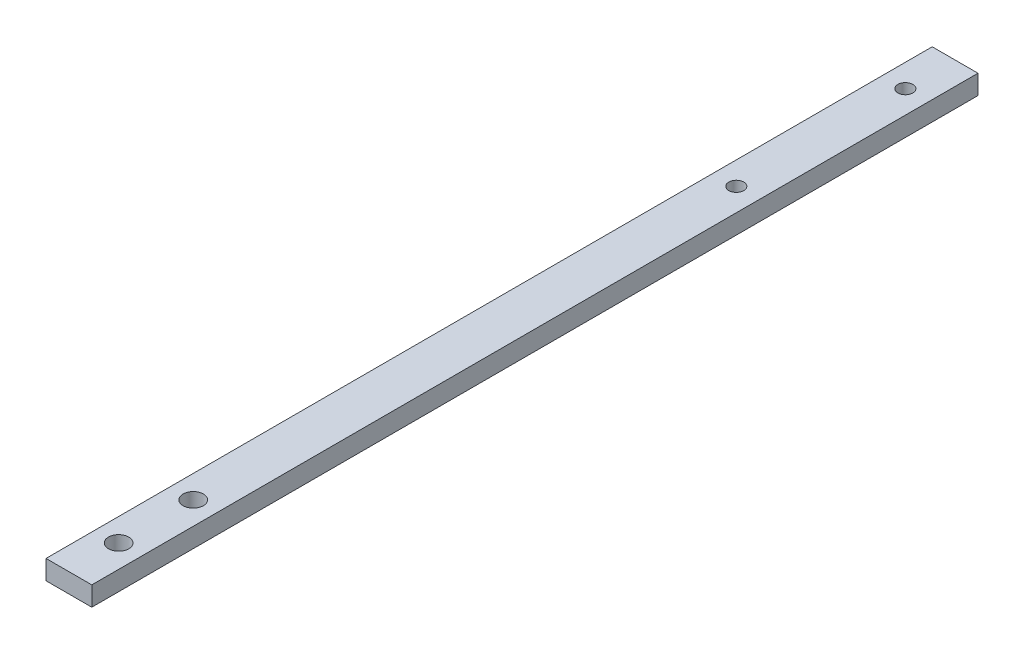
from build123d import *

# Parameters (mm, degrees)
SKETCH1_R               = 2.5
BOSS_EXTRUDE1_DEPTH     = 56
SKETCH2_W               = 4.604836256
SKETCH2_H               = 1.948199954
BOSS_EXTRUDE2_DEPTH     = 33.1
SKETCH3_R               = 1.022717979
CUT_EXTRUDE1_DEPTH      = 4.474099977
SKETCH4_R               = 0.75
CUT_EXTRUDE2_DEPTH      = 3.5
CUT_EXTRUDE2_DEPTH_BACK = 3.5
SKETCH5_OUTSIDE_W       = 24.876
SKETCH5_OUTSIDE_H       = 24.876
SKETCH5_OUTSIDE_W_2     = 4.604836256
SKETCH5_OUTSIDE_H_2     = 1.948199954
CUT_EXTRUDE3_DEPTH      = 90.1000001


with BuildPart() as part:
    # Sketch1 → Boss-Extrude1 (new body)
    with BuildSketch(Plane.XY):
        Circle(SKETCH1_R)
    extrude(amount=BOSS_EXTRUDE1_DEPTH)

    # Sketch2 → Boss-Extrude2 (add)
    with BuildSketch(Plane.XY.offset(56)):
        Rectangle(SKETCH2_W, SKETCH2_H)
    extrude(amount=BOSS_EXTRUDE2_DEPTH)

    # Sketch3 → Cut-Extrude1 (cut, through all)
    with BuildSketch(Plane(origin=(0, 0.974099977, 0), x_dir=(1, 0, 0), z_dir=(0, 1, 0))):
        with Locations((0, -76.6)):
            Circle(SKETCH3_R)
        with Locations((0, -84.1)):
            Circle(SKETCH3_R)
    extrude(amount=-CUT_EXTRUDE1_DEPTH, mode=Mode.SUBTRACT)

    # Sketch4 → Cut-Extrude2 (cut, two sides)
    with BuildSketch(Plane(origin=(0, 0, 0), x_dir=(1, 0, 0), z_dir=(0, 1, 0))) as cut_extrude2_sk:
        with Locations((0, -5)):
            Circle(SKETCH4_R)
        with Locations((0, -22)):
            Circle(SKETCH4_R)
    extrude(amount=CUT_EXTRUDE2_DEPTH, mode=Mode.SUBTRACT)
    extrude(cut_extrude2_sk.sketch, amount=-CUT_EXTRUDE2_DEPTH_BACK, mode=Mode.SUBTRACT)

    # Sketch5 outside → Cut-Extrude3 (cut, through all)
    with BuildSketch(Plane.XY.offset(89.1)):
        Rectangle(SKETCH5_OUTSIDE_W, SKETCH5_OUTSIDE_H)
        Rectangle(SKETCH5_OUTSIDE_W_2, SKETCH5_OUTSIDE_H_2, mode=Mode.SUBTRACT)
    extrude(amount=-CUT_EXTRUDE3_DEPTH, mode=Mode.SUBTRACT)


solid = part.part
